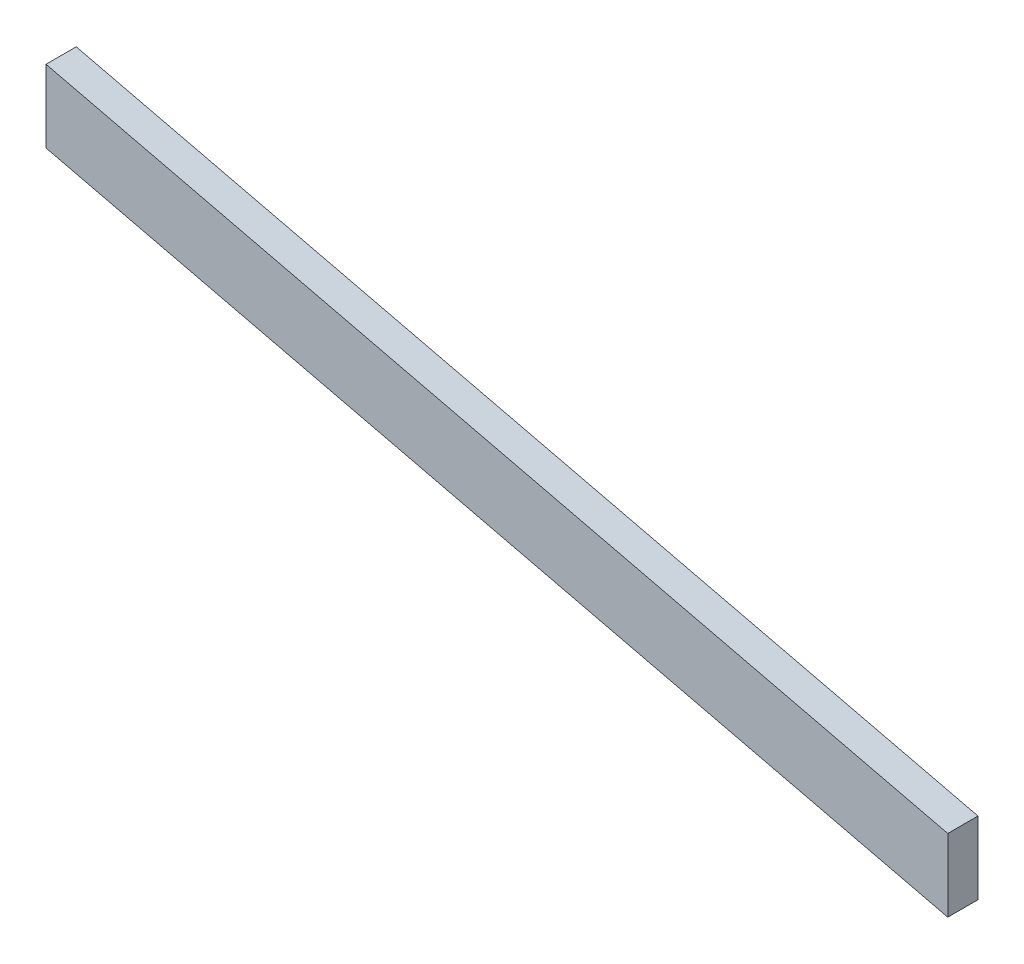
from build123d import *

# Parameters (mm, degrees)
BOSS_EXTRUDE1_DEPTH = 38.1


with BuildPart() as part:
    # Sketch1 → Boss-Extrude1 (new body)
    with BuildSketch(Plane.XY):
        Polygon((-190.793434472, 158.124120936), (945.856565528, -113.221558222), (945.856565528, -204.619629064), (-190.793434472, 66.726050094), align=None)
    extrude(amount=BOSS_EXTRUDE1_DEPTH)


solid = part.part
